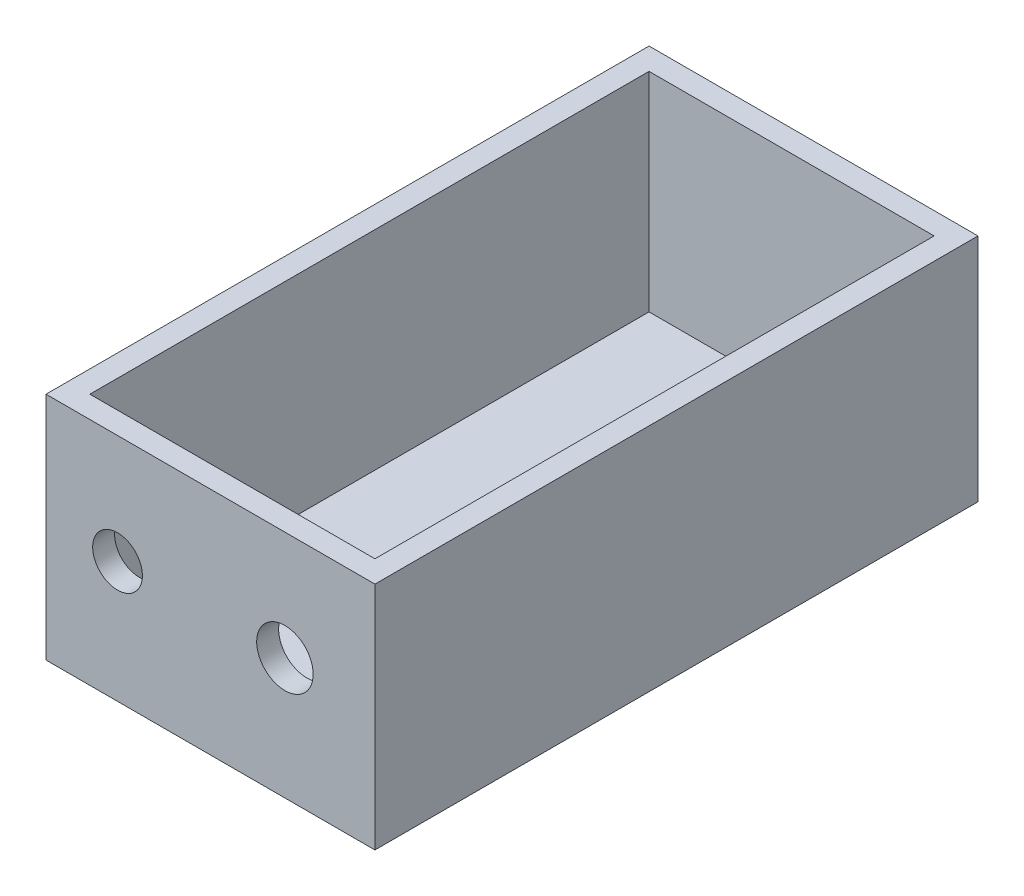
from build123d import *

# Parameters (mm, degrees)
SKETCH_1_W          = 30
SKETCH_1_H          = 55
EXTRUDE_1_DEPTH     = 21
SKETCH_2_W          = 26
SKETCH_2_H          = 51
CUT_EXTRUDE_1_DEPTH = 19
SKETCH_3_R          = 2.2671126
SKETCH_3_R_2        = 2.57383576
CUT_EXTRUDE_2_DEPTH = 3


with BuildPart() as part:
    # Эскиз1 → Бобышка-Вытянуть1 (new body)
    with BuildSketch(Plane(origin=(0, 0, 0), x_dir=(1, 0, 0), z_dir=(0, 1, 0))):
        with Locations((15, 27.5)):
            Rectangle(SKETCH_1_W, SKETCH_1_H)
    extrude(amount=EXTRUDE_1_DEPTH)

    # Эскиз2 → Вырез-Вытянуть1 (cut)
    with BuildSketch(Plane(origin=(0, 21, 0), x_dir=(1, 0, 0), z_dir=(0, 1, 0))):
        with Locations((15, 27.5)):
            Rectangle(SKETCH_2_W, SKETCH_2_H)
    extrude(amount=-CUT_EXTRUDE_1_DEPTH, mode=Mode.SUBTRACT)

    # Эскиз3 → Вырез-Вытянуть2 (cut)
    with BuildSketch(Plane.XY):
        with Locations((6.524092584, 11.054705983)):
            Circle(SKETCH_3_R)
        with Locations((21.789601228, 11.054705983)):
            Circle(SKETCH_3_R_2)
    extrude(amount=-CUT_EXTRUDE_2_DEPTH, mode=Mode.SUBTRACT)


solid = part.part
